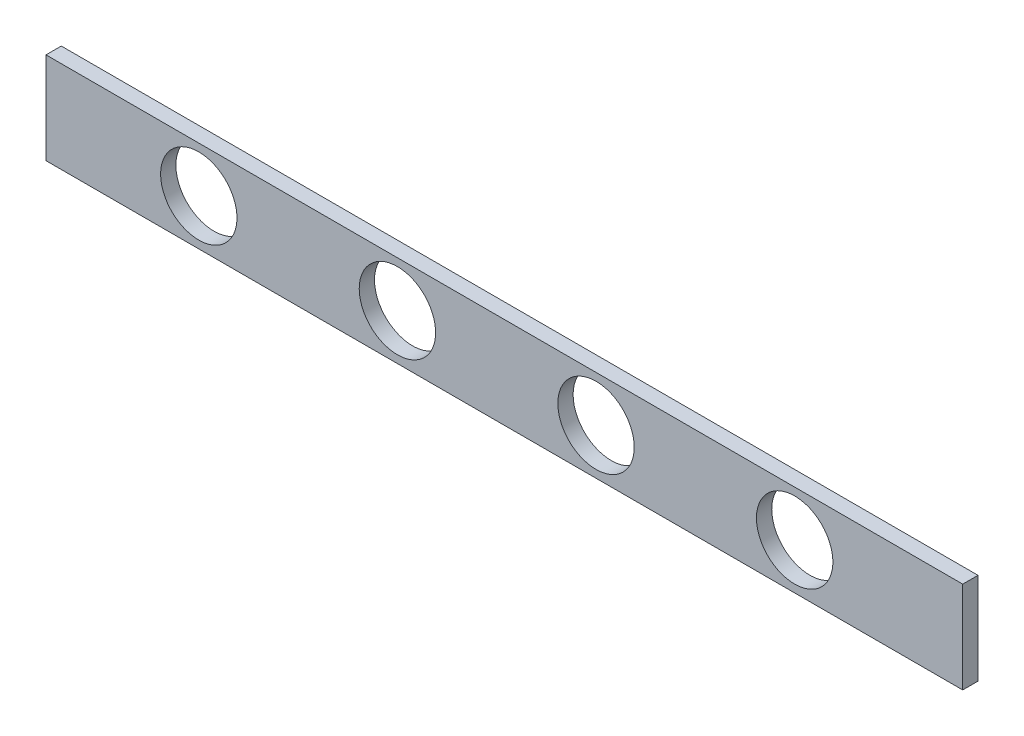
from build123d import *

# Parameters (mm, degrees)
SKETCH1_W           = 300
SKETCH1_H           = 30
BOSS_EXTRUDE1_DEPTH = 5
SKETCH2_R           = 12.5
CUT_EXTRUDE1_DEPTH  = 6


with BuildPart() as part:
    # Sketch1 → Boss-Extrude1 (new body)
    with BuildSketch(Plane.XY):
        with Locations((150, 15)):
            Rectangle(SKETCH1_W, SKETCH1_H)
    extrude(amount=BOSS_EXTRUDE1_DEPTH)

    # Sketch2 → Cut-Extrude1 (cut, through all)
    with BuildSketch(Plane(origin=(0, 0, 0), x_dir=(-1, 0, 0), z_dir=(0, 0, -1))):
        with Locations((-50, 15)):
            Circle(SKETCH2_R)
        with Locations((-115, 15)):
            Circle(SKETCH2_R)
        with Locations((-180, 15)):
            Circle(SKETCH2_R)
        with Locations((-245, 15)):
            Circle(SKETCH2_R)
    extrude(amount=-CUT_EXTRUDE1_DEPTH, mode=Mode.SUBTRACT)


solid = part.part
